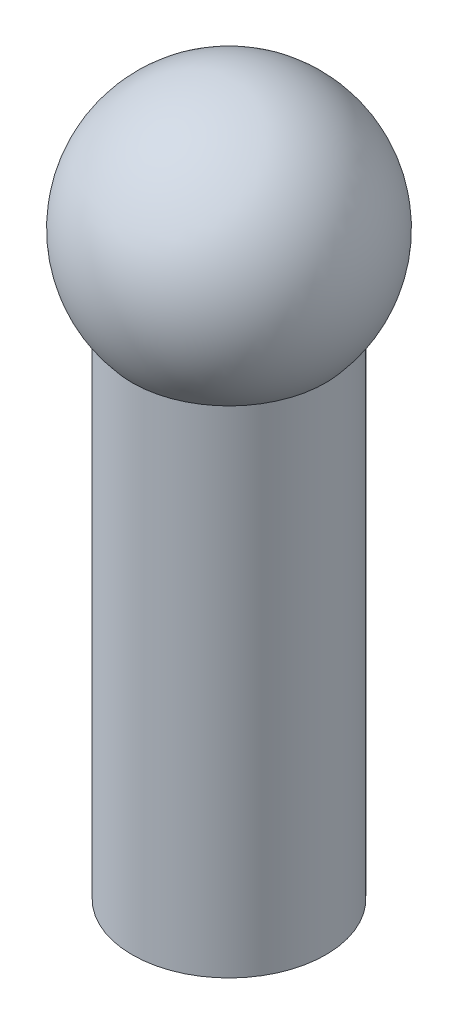
from build123d import *

# Parameters (mm, degrees)
SKETCH1_R           = 1.5
BOSS_EXTRUDE1_DEPTH = 9


with BuildPart() as part:
    # Sketch1 → Boss-Extrude1 (new body)
    with BuildSketch(Plane(origin=(0, 0, 0), x_dir=(1, 0, 0), z_dir=(0, 1, 0))):
        Circle(SKETCH1_R)
    extrude(amount=BOSS_EXTRUDE1_DEPTH)

    # Sketch2 → Revolve1 (revolve)
    with BuildSketch(Plane(origin=(0, 9, 0), x_dir=(1, 0, 0), z_dir=(0, 1, 0))):
        with BuildLine():
            Line((2, 0), (-2, 0))
            ThreePointArc((-2, 0), (0, 2), (2, 0))
        make_face()
    revolve(axis=Axis((2, 9, 0), (-1, 0, 0)))


solid = part.part
